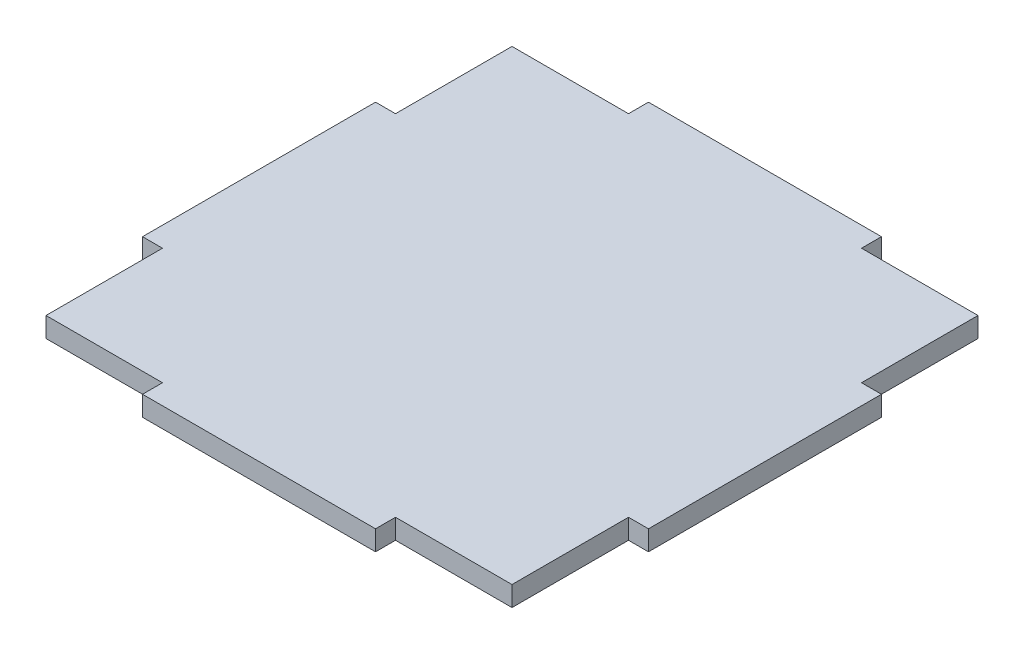
from build123d import *

# Parameters (mm, degrees)
BOSS_EXTRUDE1_DEPTH = 3


with BuildPart() as part:
    # Sketch1 → Boss-Extrude1 (new body)
    with BuildSketch(Plane(origin=(0, 0, 0), x_dir=(1, 0, 0), z_dir=(0, 1, 0))):
        Polygon((-35, -35), (-17.5, -35), (-17.5, -38), (17.5, -38), (17.5, -35), (35, -35), (35, -17.5), (38, -17.5), (38, 17.5), (35, 17.5), (35, 35), (17.5, 35), (17.5, 38), (-17.5, 38), (-17.5, 35), (-35, 35), (-35, 17.5), (-38, 17.5), (-38, -17.5), (-35, -17.5), align=None)
    extrude(amount=BOSS_EXTRUDE1_DEPTH)


solid = part.part
